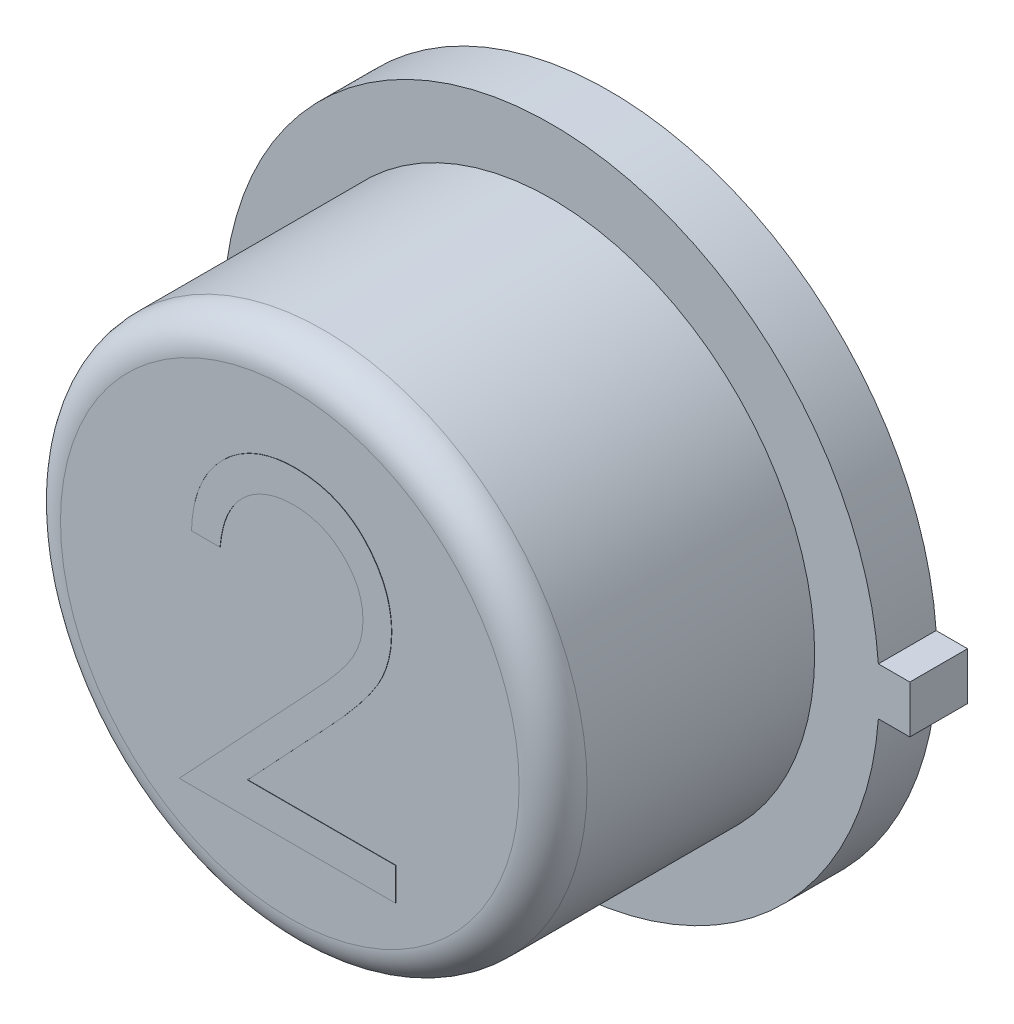
from build123d import *

# Parameters (mm, degrees)
BOSS_EXTRUDE1_DEPTH = 0.4318
SKETCH2_R           = 1.9685
BOSS_EXTRUDE2_DEPTH = 1.9558
SKETCH3_R           = 1.757566481
BOSS_EXTRUDE3_DEPTH = 0.00254
FILLET1_R           = 0.254
BOSS_EXTRUDE5_DEPTH = 0.00254


with BuildPart() as part:
    # Sketch1 → Boss-Extrude1 (new body)
    with BuildSketch(Plane.XY):
        with BuildLine():
            Line((2.6797, 0.1778), (2.4511, 0.1778))
            Line((2.4511, 0.1778), (2.44464279, 0.1778))
            ThreePointArc((2.44464279, 0.1778), (-2.4511, 0), (2.44464279, -0.1778))
            Line((2.44464279, -0.1778), (2.4511, -0.1778))
            Line((2.4511, -0.1778), (2.6797, -0.1778))
            Line((2.6797, -0.1778), (2.6797, 0.1778))
        make_face()
    extrude(amount=BOSS_EXTRUDE1_DEPTH)

    # Sketch2 → Boss-Extrude2 (add)
    with BuildSketch(Plane.XY.offset(0.4318)):
        Circle(SKETCH2_R)
    extrude(amount=BOSS_EXTRUDE2_DEPTH)

    # Sketch3 → Boss-Extrude3 (add)
    with BuildSketch(Plane(origin=(0, 0, 0), x_dir=(-1, 0, 0), z_dir=(0, 0, -1))):
        Circle(SKETCH3_R)
    extrude(amount=BOSS_EXTRUDE3_DEPTH)

    # Fillet1
    fillet1_edges = [part.edges().sort_by_distance(p)[0] for p in [
        (-1.9685, 0, 2.3876),
    ]]
    fillet(fillet1_edges, radius=FILLET1_R)

    # Sketch4 → Boss-Extrude5 (add)
    with BuildSketch(Plane.XY.offset(2.3876)):
        with BuildLine():
            Line((-0.518990385, 0.430416485), (-0.732692308, 0.430416485))
            add(Edge.make_bspline(
                [(-0.732692308, 0.430416485), (-0.731299513, 0.458767572), (-0.7285641, 0.51444835), (-0.715754139, 0.595631222), (-0.697424721, 0.673229219), (-0.671508928, 0.746619286), (-0.639323764, 0.816450331), (-0.600727084, 0.882444985), (-0.555011268, 0.94435149), (-0.503163472, 1.001595953), (-0.446851238, 1.054111068), (-0.386091304, 1.099460439), (-0.322243169, 1.137776569), (-0.255500542, 1.169808628), (-0.185110409, 1.193852344), (-0.111711536, 1.211692424), (-0.034981445, 1.222425974), (0.017297213, 1.223579714), (0.043885216, 1.224166485)],
                knots=[0, 0, 0, 0, 8.5101e-05, 0.000167136, 0.000246156, 0.000324002, 0.000400196, 0.000476525, 0.000552946, 0.00063063, 0.000707931, 0.000783585, 0.000857621, 0.000931021, 0.001005242, 0.001080329, 0.001157369, 0.0012371, 0.0012371, 0.0012371, 0.0012371], degree=3))
            add(Edge.make_bspline(
                [(0.043885216, 1.224166485), (0.069996013, 1.223555214), (0.121302796, 1.222354088), (0.196184274, 1.212039173), (0.267470255, 1.19588369), (0.335021396, 1.173217309), (0.398298736, 1.142747904), (0.457777629, 1.106146364), (0.514166181, 1.063814658), (0.564925439, 1.013975902), (0.6115354, 0.960770351), (0.651746041, 0.90396876), (0.686181069, 0.845302049), (0.714883758, 0.784322862), (0.736013024, 0.720457038), (0.752054626, 0.654634387), (0.761122027, 0.586173578), (0.762513646, 0.539836797), (0.763221154, 0.516278865)],
                knots=[0, 0, 0, 0, 7.8301e-05, 0.000153859, 0.000226296, 0.000297346, 0.000367115, 0.000436491, 0.000506613, 0.000578134, 0.000649483, 0.000718576, 0.000786562, 0.000853361, 0.000920337, 0.00098802, 0.00105636, 0.001127037, 0.001127037, 0.001127037, 0.001127037], degree=3))
            add(Edge.make_bspline(
                [(0.763221154, 0.516278865), (0.76206913, 0.483112928), (0.7597853, 0.417363068), (0.740249269, 0.320742242), (0.709737624, 0.227129576), (0.673000137, 0.151788662), (0.635939421, 0.091078017), (0.602542384, 0.041093059), (0.56344579, -0.012726912), (0.518080597, -0.070201671), (0.467385232, -0.131781412), (0.410900511, -0.197428934), (0.348223642, -0.266465977), (0.304232769, -0.313618538), (0.2814378, -0.338051814)],
                knots=[0, 0, 0, 0, 9.9412e-05, 0.00019708, 0.000294526, 0.000394158, 0.00044766, 0.000507857, 0.000574456, 0.000647169, 0.000727484, 0.000813734, 0.000906948, 0.001007195, 0.001007195, 0.001007195, 0.001007195], degree=3))
            Line((0.2814378, -0.338051814), (-0.314351713, -0.973910438))
            Line((-0.314351713, -0.973910438), (0.79375, -0.973910438))
            Line((0.79375, -0.973910438), (0.79375, -1.218141207))
            Line((0.79375, -1.218141207), (-0.824278846, -1.218141207))
            Line((-0.824278846, -1.218141207), (0.09921875, -0.232631892))
            add(Edge.make_bspline(
                [(0.09921875, -0.232631892), (0.121703116, -0.209160723), (0.164890981, -0.16407741), (0.225975199, -0.098257646), (0.28083851, -0.037195905), (0.329836058, 0.018992443), (0.371904925, 0.071129278), (0.40923764, 0.117526031), (0.439149944, 0.16022147), (0.471613454, 0.209711066), (0.503055466, 0.27013516), (0.530074051, 0.343976831), (0.546548796, 0.419991266), (0.548525122, 0.471359616), (0.549519231, 0.497198336)],
                knots=[0, 0, 0, 0, 9.7508e-05, 0.000187293, 0.000269374, 0.000343776, 0.000410901, 0.000470352, 0.000522366, 0.00056722, 0.000647868, 0.000726034, 0.000802562, 0.000880016, 0.000880016, 0.000880016, 0.000880016], degree=3))
            add(Edge.make_bspline(
                [(0.549519231, 0.497198336), (0.549086699, 0.513446216), (0.548234262, 0.545467668), (0.540711078, 0.592416229), (0.529341966, 0.637704075), (0.513050639, 0.681470511), (0.491546767, 0.723275499), (0.465371129, 0.763169928), (0.435170032, 0.80173867), (0.400232829, 0.837901896), (0.361852849, 0.871022502), (0.321307475, 0.900362281), (0.278410886, 0.924881748), (0.233343946, 0.944981877), (0.186232296, 0.960749413), (0.136984818, 0.971674983), (0.085737585, 0.978534673), (0.050744439, 0.979462797), (0.032913912, 0.979935716)],
                knots=[0, 0, 0, 0, 4.8714e-05, 9.6005e-05, 0.000142283, 0.000188622, 0.000235769, 0.000283003, 0.000331577, 0.000382519, 0.000433586, 0.000483493, 0.000532423, 0.000581535, 0.000631314, 0.000681191, 0.000732666, 0.000786145, 0.000786145, 0.000786145, 0.000786145], degree=3))
            add(Edge.make_bspline(
                [(0.032913912, 0.979935716), (0.014291971, 0.979449239), (-0.022278448, 0.978493878), (-0.075971576, 0.971810958), (-0.127192792, 0.960281735), (-0.176070944, 0.944513319), (-0.222688734, 0.924470984), (-0.266819449, 0.899507494), (-0.308364022, 0.869719082), (-0.34740055, 0.835945775), (-0.383366935, 0.798344067), (-0.414967399, 0.756427289), (-0.442579023, 0.710960779), (-0.466669948, 0.662067219), (-0.486234087, 0.609302951), (-0.501183677, 0.55285528), (-0.513012942, 0.492969305), (-0.516964811, 0.451613738), (-0.518990385, 0.430416485)],
                knots=[0, 0, 0, 0, 5.5861e-05, 0.000109703, 0.000162011, 0.00021315, 0.000263571, 0.000313981, 0.000364941, 0.000416681, 0.000468643, 0.000520734, 0.000573828, 0.000628015, 0.000684013, 0.000742333, 0.000803049, 0.000866894, 0.000866894, 0.000866894, 0.000866894], degree=3))
        make_face()
    extrude(amount=BOSS_EXTRUDE5_DEPTH)


solid = part.part
